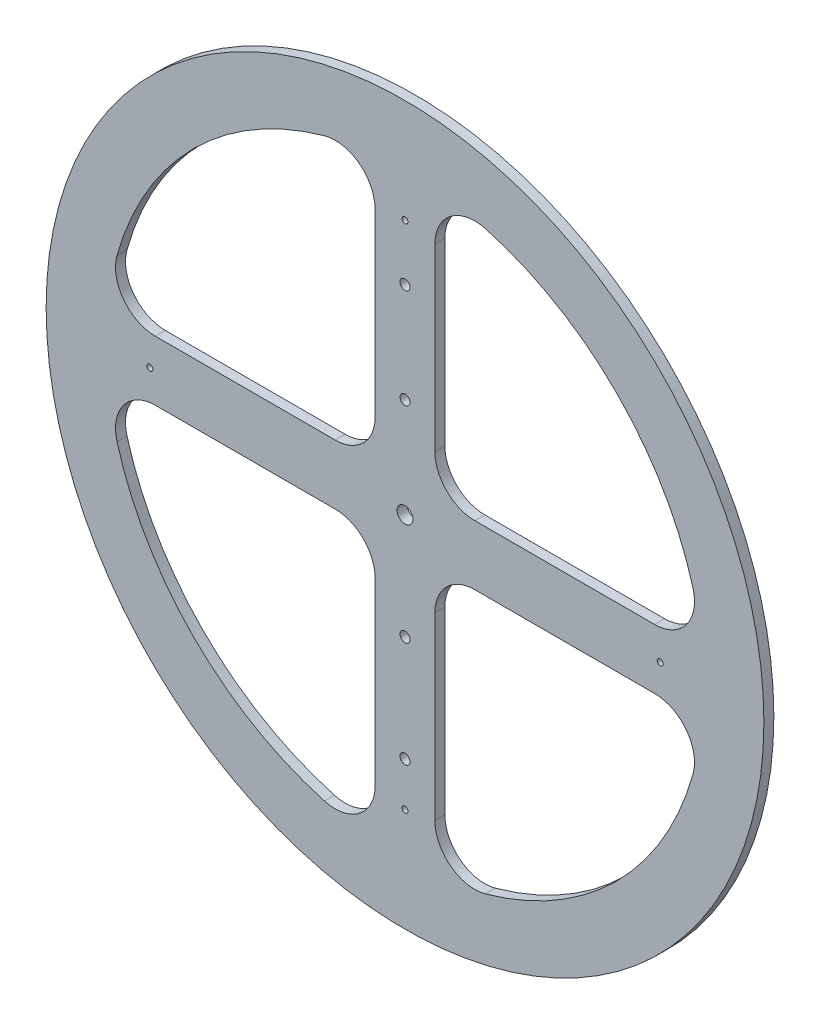
from build123d import *

# Parameters (mm, degrees)
SKETCH1_R           = 180
BOSS_EXTRUDE1_DEPTH = 5
SKETCH2_R           = 4
CUT_EXTRUDE1_DEPTH  = 6
SKETCH3_R           = 2.5
CUT_EXTRUDE2_DEPTH  = 6
SKETCH4_R           = 1.5
CUT_EXTRUDE3_DEPTH  = 6


with BuildPart() as part:
    # Sketch1 → Boss-Extrude1 (new body)
    with BuildSketch(Plane.XY):
        Circle(SKETCH1_R)
        with BuildLine():
            Line((-15, 125.199840255), (-15, 35))
            ThreePointArc((-15, 35), (-20.857864376, 20.857864376), (-35, 15))
            Line((-35, 15), (-125.199840255, 15))
            ThreePointArc((-125.199840255, 15), (-141.132390392, 22.910589503), (-144.461354141, 40.384615385))
            ThreePointArc((-144.461354141, 40.384615385), (-106.066017178, 106.066017178), (-40.384615385, 144.461354141))
            ThreePointArc((-40.384615385, 144.461354141), (-22.910589503, 141.132390392), (-15, 125.199840255))
        make_face(mode=Mode.SUBTRACT)
        with BuildLine():
            Line((15, 125.199840255), (15, 35))
            ThreePointArc((15, 35), (20.857864376, 20.857864376), (35, 15))
            Line((35, 15), (125.199840255, 15))
            ThreePointArc((125.199840255, 15), (141.132390392, 22.910589503), (144.461354141, 40.384615385))
            ThreePointArc((144.461354141, 40.384615385), (106.066017178, 106.066017178), (40.384615385, 144.461354141))
            ThreePointArc((40.384615385, 144.461354141), (22.910589503, 141.132390392), (15, 125.199840255))
        make_face(mode=Mode.SUBTRACT)
        with BuildLine():
            Line((125.199840255, -15), (35, -15))
            ThreePointArc((35, -15), (20.857864376, -20.857864376), (15, -35))
            Line((15, -35), (15, -125.199840255))
            ThreePointArc((15, -125.199840255), (22.910589503, -141.132390392), (40.384615385, -144.461354141))
            ThreePointArc((40.384615385, -144.461354141), (106.066017178, -106.066017178), (144.461354141, -40.384615385))
            ThreePointArc((144.461354141, -40.384615385), (141.132390392, -22.910589503), (125.199840255, -15))
        make_face(mode=Mode.SUBTRACT)
        with BuildLine():
            Line((-15, -35), (-15, -125.199840255))
            ThreePointArc((-15, -125.199840255), (-22.910589503, -141.132390392), (-40.384615385, -144.461354141))
            ThreePointArc((-40.384615385, -144.461354141), (-106.066017178, -106.066017178), (-144.461354141, -40.384615385))
            ThreePointArc((-144.461354141, -40.384615385), (-141.132390392, -22.910589503), (-125.199840255, -15))
            Line((-125.199840255, -15), (-35, -15))
            ThreePointArc((-35, -15), (-20.857864376, -20.857864376), (-15, -35))
        make_face(mode=Mode.SUBTRACT)
    extrude(amount=BOSS_EXTRUDE1_DEPTH)

    # Sketch2 → Cut-Extrude1 (cut, through all)
    with BuildSketch(Plane.XY.offset(5)):
        Circle(SKETCH2_R)
    extrude(amount=-CUT_EXTRUDE1_DEPTH, mode=Mode.SUBTRACT)

    # Sketch3 → Cut-Extrude2 (cut, through all)
    with BuildSketch(Plane.XY.offset(5)):
        with Locations((0, 50)):
            Circle(SKETCH3_R)
        with Locations((0, 100)):
            Circle(SKETCH3_R)
        with Locations((0, -53)):
            Circle(SKETCH3_R)
        with Locations((0, -106)):
            Circle(SKETCH3_R)
    extrude(amount=-CUT_EXTRUDE2_DEPTH, mode=Mode.SUBTRACT)

    # Sketch4 → Cut-Extrude3 (cut, through all)
    with BuildSketch(Plane.XY.offset(5)):
        with Locations((0, 128)):
            Circle(SKETCH4_R)
        with Locations((128, 0)):
            Circle(SKETCH4_R)
        with Locations((0, -128)):
            Circle(SKETCH4_R)
        with Locations((-128, 0)):
            Circle(SKETCH4_R)
    extrude(amount=-CUT_EXTRUDE3_DEPTH, mode=Mode.SUBTRACT)


solid = part.part
